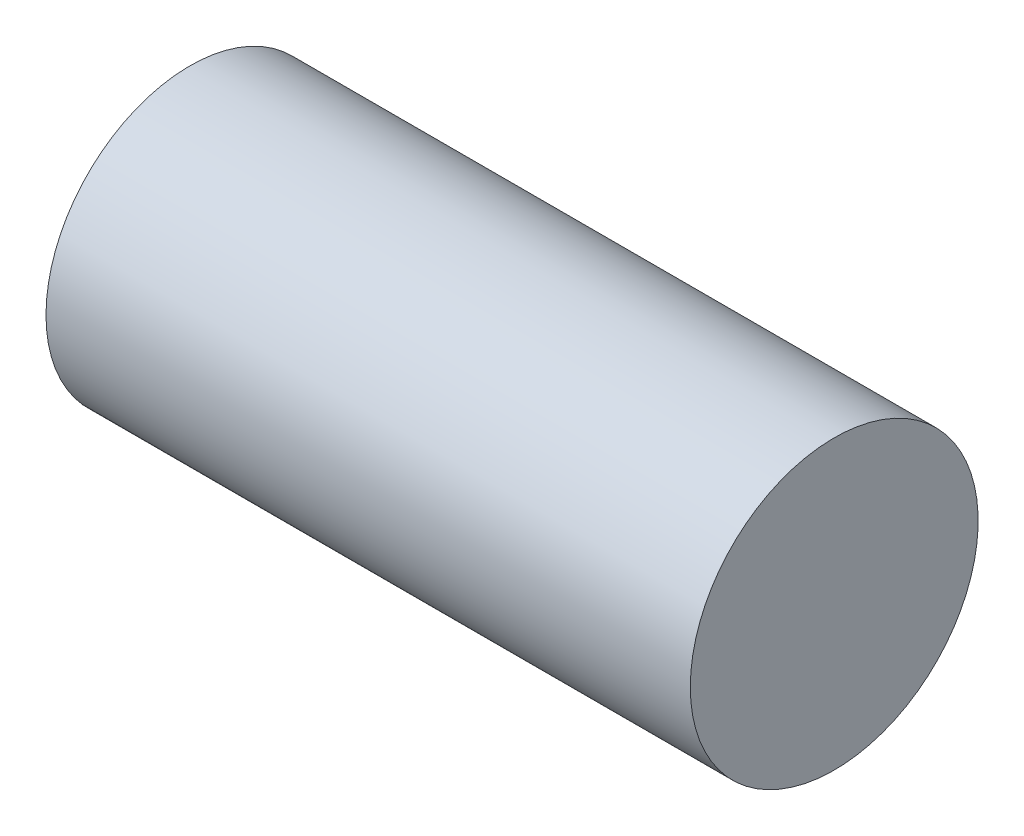
from build123d import *

# Parameters (mm, degrees)
SKETCH_1_R      = 13.403118467
EXTRUDE_1_DEPTH = 60


with BuildPart() as part:
    # 草图1 → 凸台-拉伸1 (new body)
    with BuildSketch(Plane.ZY.offset(-56.720720721)):
        with Locations((61.707987888, -76.630201051)):
            Circle(SKETCH_1_R)
    extrude(amount=EXTRUDE_1_DEPTH)


solid = part.part
